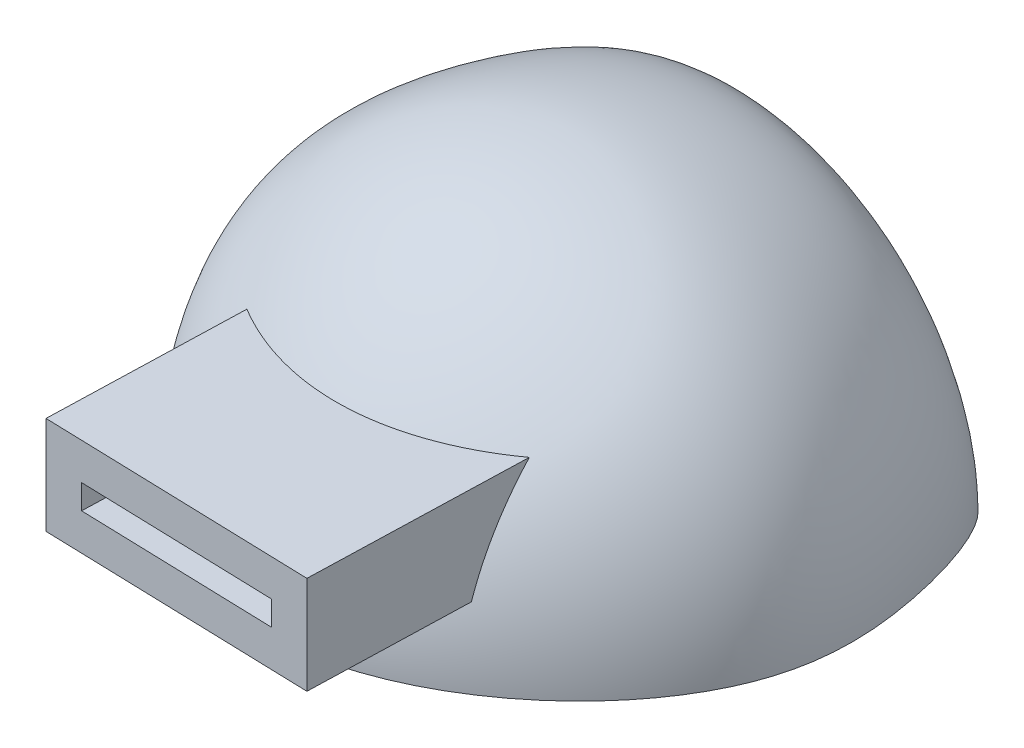
from build123d import *

# Parameters (mm, degrees)
REVOLVE1_ANGLE           = 180
SKETCH3_W                = 69.85
SKETCH3_H                = 25.4
SKETCH3_W_2              = 50.8
SKETCH3_H_2              = 6.35
BOSS_EXTRUDE7_DEPTH      = 25.4
BOSS_EXTRUDE7_DEPTH_BACK = 38.1


with BuildPart() as part:
    # Sketch2 → Revolve1 (revolve)
    with BuildSketch(Plane(origin=(0, 0, 0), x_dir=(1, 0, 0), z_dir=(0, 1, 0))):
        with BuildLine():
            Line((32.496202247, -75.759218491), (32.496202247, -102.830579492))
            add(Edge.make_bspline(
                [(82.058028303, 7.870345482), (93.041481389, 34.162455024), (112.348086196, -13.725828539), (106.284293116, -68.651897164), (61.355001648, -101.966794635), (32.496202247, -102.830579492)],
                knots=[0, 0, 0, 0, 0.26758911, 0.512711999, 1, 1, 1, 1], degree=3))
            ThreePointArc((82.058028303, 7.870345482), (70.916457376, -42.027591177), (32.496202247, -75.759218491))
        make_face()
    revolve(axis=Axis((32.496202247, 0, 75.759218491), (0, 0, 1)), revolution_arc=REVOLVE1_ANGLE)

    # Sketch3 → Boss-Extrude7 (add, two sides)
    with BuildSketch(Plane(origin=(32.496202247, 0, 102.830579492), x_dir=(0.999552356, 0, 0.029918022), z_dir=(-0.029918022, 0, 0.999552356))) as boss_extrude7_sk:
        with Locations((1.700295248, 31.70443969)):
            Rectangle(SKETCH3_W, SKETCH3_H)
        with Locations((1.700295248, 31.70443969)):
            Rectangle(SKETCH3_W_2, SKETCH3_H_2, mode=Mode.SUBTRACT)
    extrude(amount=BOSS_EXTRUDE7_DEPTH)
    extrude(boss_extrude7_sk.sketch, amount=-BOSS_EXTRUDE7_DEPTH_BACK)


solid = part.part
